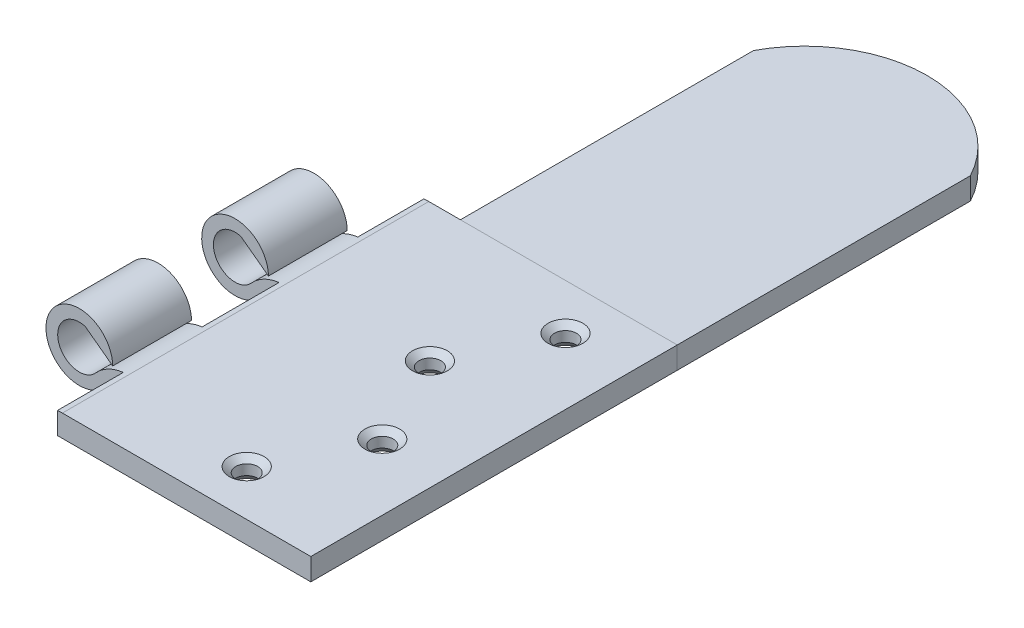
from build123d import *

# Parameters (mm, degrees)
BOSS_EXTRUDE1_DEPTH     = 25
SKETCH2_W               = 12
SKETCH2_H               = 10.5
SKETCH2_H_2             = 9.5
CUT_EXTRUDE1_DEPTH      = 6
CUT_EXTRUDE1_DEPTH_BACK = 6
SKETCH3_R               = 1.5
CUT_EXTRUDE2_DEPTH      = 6
CHAMFER1_SIZE           = 0.875
CHAMFER1_SIZE2          = 0.734212177
CHAMFER1_PART_2_SIZE    = 0.875
CHAMFER1_PART_2_SIZE2   = 0.734212177
CHAMFER1_PART_3_SIZE    = 0.875
CHAMFER1_PART_3_SIZE2   = 0.734212177
CHAMFER1_PART_4_SIZE    = 0.875
CHAMFER1_PART_4_SIZE2   = 0.734212177
CHAMFER1_PART_5_SIZE    = 0.875
CHAMFER1_PART_5_SIZE2   = 0.734212177
BOSS_EXTRUDE2_DEPTH     = 3


with BuildPart() as part:
    # Sketch1 → Boss-Extrude1 (new body, symmetric)
    with BuildSketch(Plane.XY):
        with BuildLine():
            Line((5.587128064, -2.955), (40.587128064, -2.955))
            Line((40.587128064, -2.955), (40.587128064, 0.045))
            Line((40.587128064, 0.045), (6.688049043, 0.045))
            ThreePointArc((6.688049043, 0.045), (4.232412516, -0.480527492), (2.206944157, -1.965050251))
            ThreePointArc((2.206944157, -1.965050251), (-2.834596442, -0.834917966), (0.789396387, 2.847609233))
            Line((0.789396387, 2.847609233), (4.554777711, 0.045))
            ThreePointArc((4.554777711, 0.045), (-3.993998166, 2.189978003), (2.41111969, -3.864521554))
            ThreePointArc((2.41111969, -3.864521554), (3.93529131, -3.186860323), (5.587128064, -2.955))
        make_face()
    extrude(amount=BOSS_EXTRUDE1_DEPTH, both=True)

    # Sketch2 → Cut-Extrude1 (cut, two sides)
    with BuildSketch(Plane(origin=(0, 0, 0), x_dir=(1, 0, 0), z_dir=(0, 1, 0))) as cut_extrude1_sk:
        Rectangle(SKETCH2_W, SKETCH2_H)
        with Locations((0, 20.75)):
            Rectangle(SKETCH2_W, SKETCH2_H_2)
        with Locations((0, -20.75)):
            Rectangle(SKETCH2_W, SKETCH2_H_2)
    extrude(amount=CUT_EXTRUDE1_DEPTH, mode=Mode.SUBTRACT)
    extrude(cut_extrude1_sk.sketch, amount=-CUT_EXTRUDE1_DEPTH_BACK, mode=Mode.SUBTRACT)

    # Sketch3 → Cut-Extrude2 (cut)
    with BuildSketch(Plane(origin=(0, 0.045, 0), x_dir=(1, 0, 0), z_dir=(0, 1, 0))):
        with Locations((31.587128064, 18.75)):
            Circle(SKETCH3_R)
        with Locations((25.587128064, 6.25)):
            Circle(SKETCH3_R)
        with Locations((31.587128064, -6.25)):
            Circle(SKETCH3_R)
        with Locations((25.587128064, -18.75)):
            Circle(SKETCH3_R)
    extrude(amount=-CUT_EXTRUDE2_DEPTH, mode=Mode.SUBTRACT)

    # Chamfer1
    chamfer1_edges = [part.edges().sort_by_distance(p)[0] for p in [
        (30.087128064, -2.955, 6.25),
    ]]
    chamfer1_side = [part.faces().sort_by_distance(p)[0] for p in [
        (30.087128064, -1.455, 6.25),
    ]]
    chamfer(chamfer1_edges, length=CHAMFER1_SIZE, length2=CHAMFER1_SIZE2, reference=chamfer1_side[0])

    # Chamfer1 part 2
    chamfer1_part_2_edges = [part.edges().sort_by_distance(p)[0] for p in [
        (30.087128064, 0.045, 6.25),
        (24.087128064, 0.045, 18.75),
        (30.087128064, 0.045, -18.75),
        (24.087128064, 0.045, -6.25),
    ]]
    chamfer1_part_2_side = [part.faces().sort_by_distance(p)[0] for p in [
        (23.553622246, 0.045, 0),
    ]]
    chamfer(chamfer1_part_2_edges, length=CHAMFER1_PART_2_SIZE, length2=CHAMFER1_PART_2_SIZE2, reference=chamfer1_part_2_side[0])

    # Chamfer1 part 3
    chamfer1_part_3_edges = [part.edges().sort_by_distance(p)[0] for p in [
        (24.087128064, -2.955, 18.75),
    ]]
    chamfer1_part_3_side = [part.faces().sort_by_distance(p)[0] for p in [
        (24.087128064, -1.455, 18.75),
    ]]
    chamfer(chamfer1_part_3_edges, length=CHAMFER1_PART_3_SIZE, length2=CHAMFER1_PART_3_SIZE2, reference=chamfer1_part_3_side[0])

    # Chamfer1 part 4
    chamfer1_part_4_edges = [part.edges().sort_by_distance(p)[0] for p in [
        (30.087128064, -2.955, -18.75),
    ]]
    chamfer1_part_4_side = [part.faces().sort_by_distance(p)[0] for p in [
        (30.087128064, -1.455, -18.75),
    ]]
    chamfer(chamfer1_part_4_edges, length=CHAMFER1_PART_4_SIZE, length2=CHAMFER1_PART_4_SIZE2, reference=chamfer1_part_4_side[0])

    # Chamfer1 part 5
    chamfer1_part_5_edges = [part.edges().sort_by_distance(p)[0] for p in [
        (24.087128064, -2.955, -6.25),
    ]]
    chamfer1_part_5_side = [part.faces().sort_by_distance(p)[0] for p in [
        (24.087128064, -1.455, -6.25),
    ]]
    chamfer(chamfer1_part_5_edges, length=CHAMFER1_PART_5_SIZE, length2=CHAMFER1_PART_5_SIZE2, reference=chamfer1_part_5_side[0])


with BuildPart() as body_2:
    # Sketch4 → Boss-Extrude2 (new body)
    with BuildSketch(Plane.XZ.offset(2.955)):
        with BuildLine():
            Line((40.587128064, -25), (11, -25))
            Line((11, -25), (11, -65))
            ThreePointArc((11, -65), (25.793564032, -73.894240124), (40.587128064, -65))
            Line((40.587128064, -65), (40.587128064, -25))
        make_face()
    extrude(amount=-BOSS_EXTRUDE2_DEPTH)


solid = Compound([part.part, body_2.part])
